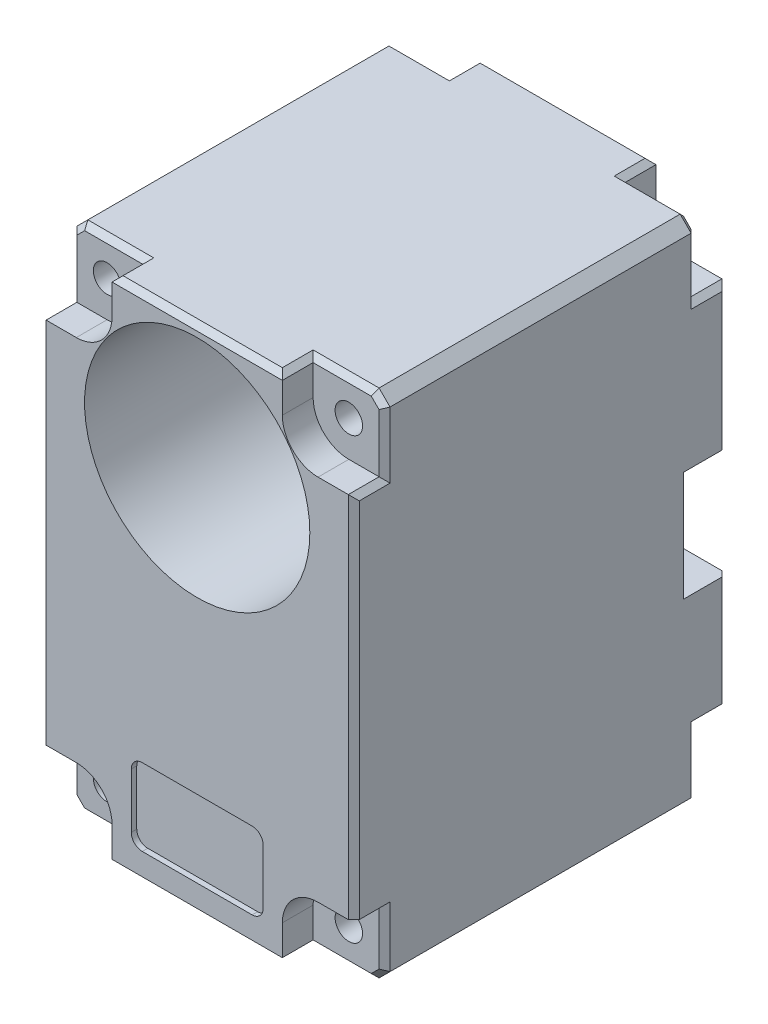
from build123d import *

# Parameters (mm, degrees)
SKETCH1_W           = 28.5
SKETCH1_H           = 46.5
BOSS_EXTRUDE1_DEPTH = 34
SKETCH2_R           = 10.25
CUT_EXTRUDE1_DEPTH  = 35
SKETCH3_R           = 1.25
CUT_EXTRUDE2_DEPTH  = 10
CUT_EXTRUDE3_DEPTH  = 0.5
CUT_EXTRUDE4_DEPTH  = 2.8
SKETCH6_W           = 28.5
SKETCH6_H           = 10
CUT_EXTRUDE5_DEPTH  = 4
CHAMFER1_SIZE       = 1
CHAMFER2_SIZE       = 0.5
CHAMFER3_SIZE       = 0.5


with BuildPart() as part:
    # Sketch1 → Boss-Extrude1 (new body)
    with BuildSketch(Plane.XY):
        Rectangle(SKETCH1_W, SKETCH1_H)
    extrude(amount=BOSS_EXTRUDE1_DEPTH)

    # Sketch2 → Cut-Extrude1 (cut, through all)
    with BuildSketch(Plane.XY.offset(34)):
        with Locations((0, 12)):
            Circle(SKETCH2_R)
    extrude(amount=-CUT_EXTRUDE1_DEPTH, mode=Mode.SUBTRACT)

    # Sketch3 → Cut-Extrude2 (cut)
    with BuildSketch(Plane.XY.offset(34)):
        with Locations((-11, 20)):
            Circle(SKETCH3_R)
        with Locations((11, 20)):
            Circle(SKETCH3_R)
        with Locations((11, -20)):
            Circle(SKETCH3_R)
        with Locations((-11, -20)):
            Circle(SKETCH3_R)
    cut_extrude2 = extrude(amount=-CUT_EXTRUDE2_DEPTH, mode=Mode.SUBTRACT)

    # Sketch4 → Cut-Extrude3 (cut)
    with BuildSketch(Plane.XY.offset(34)):
        with BuildLine():
            Line((-5, -20.75), (5, -20.75))
            ThreePointArc((5, -20.75), (5.707106781, -20.457106781), (6, -19.75))
            Line((6, -19.75), (6, -14.75))
            ThreePointArc((6, -14.75), (5.707106781, -14.042893219), (5, -13.75))
            Line((5, -13.75), (-5, -13.75))
            ThreePointArc((-5, -13.75), (-5.707106781, -14.042893219), (-6, -14.75))
            Line((-6, -14.75), (-6, -19.75))
            ThreePointArc((-6, -19.75), (-5.707106781, -20.457106781), (-5, -20.75))
        make_face()
    extrude(amount=-CUT_EXTRUDE3_DEPTH, mode=Mode.SUBTRACT)

    # Sketch5 → Cut-Extrude4 (cut)
    with BuildSketch(Plane.XY.offset(34)):
        with BuildLine():
            Line((-7.75, 23.25), (-11, 23.25))
            ThreePointArc((-11, 23.25), (-8.701902961, 22.298097039), (-7.75, 20))
            Line((-7.75, 20), (-7.75, 23.25))
        make_face()
        with BuildLine():
            Line((-11, 23.25), (-14.25, 23.25))
            Line((-14.25, 23.25), (-14.25, 20))
            ThreePointArc((-14.25, 20), (-13.298097039, 22.298097039), (-11, 23.25))
        make_face()
        with BuildLine():
            ThreePointArc((-11, 16.75), (-13.298097039, 17.701902961), (-14.25, 20))
            Line((-14.25, 20), (-14.25, 16.75))
            Line((-14.25, 16.75), (-11, 16.75))
        make_face()
        with BuildLine():
            Line((-12.25, 20), (-14.25, 20))
            ThreePointArc((-14.25, 20), (-13.298097039, 17.701902961), (-11, 16.75))
            Line((-11, 16.75), (-11, 18.75))
            ThreePointArc((-11, 18.75), (-11.883883476, 19.116116524), (-12.25, 20))
        make_face()
        with BuildLine():
            ThreePointArc((-11, 16.75), (-8.701902961, 17.701902961), (-7.75, 20))
            Line((-7.75, 20), (-9.75, 20))
            ThreePointArc((-9.75, 20), (-10.116116524, 19.116116524), (-11, 18.75))
            Line((-11, 18.75), (-11, 16.75))
        make_face()
        with BuildLine():
            ThreePointArc((-7.75, 20), (-8.701902961, 22.298097039), (-11, 23.25))
            ThreePointArc((-11, 23.25), (-13.298097039, 22.298097039), (-14.25, 20))
            Line((-14.25, 20), (-12.25, 20))
            ThreePointArc((-12.25, 20), (-11, 21.25), (-9.75, 20))
            Line((-9.75, 20), (-7.75, 20))
        make_face()
        with BuildLine():
            Line((11, 23.25), (7.75, 23.25))
            Line((7.75, 23.25), (7.75, 20))
            ThreePointArc((7.75, 20), (8.701902961, 22.298097039), (11, 23.25))
        make_face()
        with BuildLine():
            Line((14.25, 23.25), (11, 23.25))
            ThreePointArc((11, 23.25), (13.298097039, 22.298097039), (14.25, 20))
            Line((14.25, 20), (14.25, 23.25))
        make_face()
        with BuildLine():
            ThreePointArc((14.25, 20), (13.298097039, 17.701902961), (11, 16.75))
            Line((11, 16.75), (14.25, 16.75))
            Line((14.25, 16.75), (14.25, 20))
        make_face()
        with BuildLine():
            Line((9.75, 20), (7.75, 20))
            ThreePointArc((7.75, 20), (8.701902961, 17.701902961), (11, 16.75))
            Line((11, 16.75), (11, 18.75))
            ThreePointArc((11, 18.75), (10.116116524, 19.116116524), (9.75, 20))
        make_face()
        with BuildLine():
            Line((11, 18.75), (11, 16.75))
            ThreePointArc((11, 16.75), (13.298097039, 17.701902961), (14.25, 20))
            Line((14.25, 20), (12.25, 20))
            ThreePointArc((12.25, 20), (11.883883476, 19.116116524), (11, 18.75))
        make_face()
        with BuildLine():
            ThreePointArc((11, 23.25), (8.701902961, 22.298097039), (7.75, 20))
            Line((7.75, 20), (9.75, 20))
            ThreePointArc((9.75, 20), (11, 21.25), (12.25, 20))
            Line((12.25, 20), (14.25, 20))
            ThreePointArc((14.25, 20), (13.298097039, 22.298097039), (11, 23.25))
        make_face()
        with BuildLine():
            ThreePointArc((-11, -16.75), (-13.298097039, -17.701902961), (-14.25, -20))
            Line((-14.25, -20), (-12.25, -20))
            ThreePointArc((-12.25, -20), (-11.883883476, -19.116116524), (-11, -18.75))
            Line((-11, -18.75), (-11, -16.75))
        make_face()
        with BuildLine():
            ThreePointArc((-7.75, -20), (-8.701902961, -17.701902961), (-11, -16.75))
            Line((-11, -16.75), (-11, -18.75))
            ThreePointArc((-11, -18.75), (-10.116116524, -19.116116524), (-9.75, -20))
            Line((-9.75, -20), (-7.75, -20))
        make_face()
        with BuildLine():
            Line((-12.25, -20), (-14.25, -20))
            ThreePointArc((-14.25, -20), (-13.298097039, -22.298097039), (-11, -23.25))
            ThreePointArc((-11, -23.25), (-8.701902961, -22.298097039), (-7.75, -20))
            Line((-7.75, -20), (-9.75, -20))
            ThreePointArc((-9.75, -20), (-11, -21.25), (-12.25, -20))
        make_face()
        with BuildLine():
            Line((-11, -16.75), (-14.25, -16.75))
            Line((-14.25, -16.75), (-14.25, -20))
            ThreePointArc((-14.25, -20), (-13.298097039, -17.701902961), (-11, -16.75))
        make_face()
        with BuildLine():
            ThreePointArc((-11, -23.25), (-13.298097039, -22.298097039), (-14.25, -20))
            Line((-14.25, -20), (-14.25, -23.25))
            Line((-14.25, -23.25), (-11, -23.25))
        make_face()
        with BuildLine():
            ThreePointArc((-7.75, -20), (-8.701902961, -22.298097039), (-11, -23.25))
            Line((-11, -23.25), (-7.75, -23.25))
            Line((-7.75, -23.25), (-7.75, -20))
        make_face()
        with BuildLine():
            Line((7.75, -20), (7.75, -23.25))
            Line((7.75, -23.25), (11, -23.25))
            ThreePointArc((11, -23.25), (8.701902961, -22.298097039), (7.75, -20))
        make_face()
        with BuildLine():
            ThreePointArc((11, -23.25), (13.298097039, -22.298097039), (14.25, -20))
            Line((14.25, -20), (12.25, -20))
            ThreePointArc((12.25, -20), (11, -21.25), (9.75, -20))
            Line((9.75, -20), (7.75, -20))
            ThreePointArc((7.75, -20), (8.701902961, -22.298097039), (11, -23.25))
        make_face()
        with BuildLine():
            Line((14.25, -23.25), (14.25, -20))
            ThreePointArc((14.25, -20), (13.298097039, -22.298097039), (11, -23.25))
            Line((11, -23.25), (14.25, -23.25))
        make_face()
        with BuildLine():
            ThreePointArc((14.25, -20), (13.298097039, -17.701902961), (11, -16.75))
            Line((11, -16.75), (11, -18.75))
            ThreePointArc((11, -18.75), (11.883883476, -19.116116524), (12.25, -20))
            Line((12.25, -20), (14.25, -20))
        make_face()
        with BuildLine():
            Line((11, -18.75), (11, -16.75))
            ThreePointArc((11, -16.75), (8.701902961, -17.701902961), (7.75, -20))
            Line((7.75, -20), (9.75, -20))
            ThreePointArc((9.75, -20), (10.116116524, -19.116116524), (11, -18.75))
        make_face()
        with BuildLine():
            Line((14.25, -20), (14.25, -16.75))
            Line((14.25, -16.75), (11, -16.75))
            ThreePointArc((11, -16.75), (13.298097039, -17.701902961), (14.25, -20))
        make_face()
    cut_extrude4 = extrude(amount=-CUT_EXTRUDE4_DEPTH, mode=Mode.SUBTRACT)

    # Mirror1: Cut-Extrude4 across plane
    add(cut_extrude4.mirror(Plane.XY.offset(17)), mode=Mode.SUBTRACT)

    # Mirror2: Cut-Extrude2 across plane
    add(cut_extrude2.mirror(Plane.XY.offset(17)), mode=Mode.SUBTRACT)

    # Sketch6 → Cut-Extrude5 (cut)
    with BuildSketch(Plane(origin=(0, 0, 0), x_dir=(-1, 0, 0), z_dir=(0, 0, -1))):
        with Locations((0, -1.25)):
            Rectangle(SKETCH6_W, SKETCH6_H)
    extrude(amount=-CUT_EXTRUDE5_DEPTH, mode=Mode.SUBTRACT)

    # Chamfer1
    chamfer1_edges = [part.edges().sort_by_distance(p)[0] for p in [
        (14.25, -23.25, 17),
        (-14.25, -23.25, 17),
        (-14.25, 23.25, 17),
        (14.25, 23.25, 17),
    ]]
    chamfer(chamfer1_edges, length=CHAMFER1_SIZE)

    # Chamfer2
    chamfer2_edges = [part.edges().sort_by_distance(p)[0] for p in [
        (-14.25, 10.25, 0),
        (0, 23.25, 0),
        (7.75, 23.25, 1.4),
        (14.25, 16.75, 1.4),
        (14.25, 19.5, 2.8),
        (-14.25, 16.75, 1.4),
        (-10.5, 23.25, 2.8),
        (14.25, 10.25, 0),
        (-14.25, 19.5, 2.8),
        (-13.75, 22.75, 2.8),
        (10.5, 23.25, 2.8),
        (13.75, 22.75, 2.8),
    ]]
    chamfer(chamfer2_edges, length=CHAMFER2_SIZE)

    # Chamfer3
    chamfer3_edges = [part.edges().sort_by_distance(p)[0] for p in [
        (-9.916381265, 3.75, 0),
        (9.916381265, 3.75, 0),
        (-14.25, -11.5, 0),
        (-14.25, -19.5, 2.8),
        (-13.75, -22.75, 31.2),
        (-13.75, -22.75, 2.8),
        (-10.5, -23.25, 2.8),
        (-7.75, -23.25, 1.4),
        (14.25, -11.5, 0),
        (14.25, -16.75, 1.4),
        (0, -23.25, 0),
        (7.75, -23.25, 1.4),
        (10.5, -23.25, 2.8),
        (14.25, -19.5, 2.8),
        (13.75, -22.75, 31.2),
        (13.75, -22.75, 2.8),
        (-14.25, -19.5, 31.2),
        (-10.5, -23.25, 31.2),
        (-7.75, -23.25, 32.6),
        (0, -23.25, 34),
        (7.75, -23.25, 32.6),
        (14.25, -19.5, 31.2),
        (10.5, -23.25, 31.2),
        (14.25, 0, 34),
        (14.25, 16.75, 32.6),
        (14.25, 19.5, 31.2),
        (13.75, 22.75, 31.2),
        (10.5, 23.25, 31.2),
        (7.75, 23.25, 32.6),
        (0, 23.25, 34),
        (-7.75, 23.25, 32.6),
        (-14.25, 0, 34),
        (-14.25, 16.75, 32.6),
        (-14.25, 19.5, 31.2),
        (-13.75, 22.75, 31.2),
        (-10.5, 23.25, 31.2),
    ]]
    chamfer(chamfer3_edges, length=CHAMFER3_SIZE)


solid = part.part
